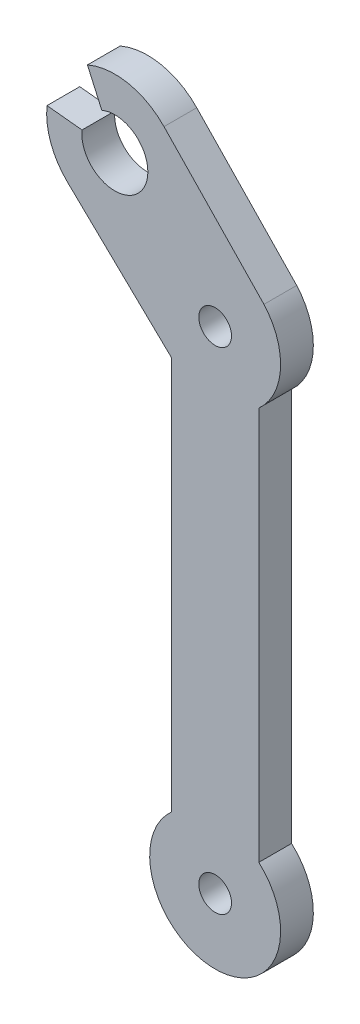
from build123d import *

# Parameters (mm, degrees)
ESQUISSE1_R        = 1.5
BOSS_EXTRU_1_DEPTH = 3


with BuildPart() as part:
    # Esquisse1 → Boss.-Extru.1 (new body)
    with BuildSketch(Plane.XY):
        with BuildLine():
            Line((-10.438754388, 20.283961606), (-10.438754388, -0.112631187))
            Line((-10.438754388, -0.112631187), (-10.438754388, -15.771766484))
            ThreePointArc((-10.438754388, -15.771766484), (-6.438754388, -26.243902439), (-2.438754388, -15.771766484))
            Line((-2.438754388, -15.771766484), (-2.438754388, 20.283961606))
            ThreePointArc((-2.438754388, 20.283961606), (-0.448049603, 24.422247026), (-1.966618433, 28.756097561))
            Line((-1.966618433, 28.756097561), (-2.267139353, 29.068594286))
            Line((-2.267139353, 29.068594286), (-11.126247763, 38.28073952))
            ThreePointArc((-11.126247763, 38.28073952), (-14.416088568, 40.079239654), (-18.143198107, 39.671428739))
            Line((-18.143198107, 39.671428739), (-16.826364742, 36.727346795))
            ThreePointArc((-16.826364742, 36.727346795), (-13.967550368, 36.474962725), (-12.606142543, 33.948485716))
            ThreePointArc((-12.606142543, 33.948485716), (-15.786873062, 30.92749697), (-18.640108166, 34.259533746))
            Line((-18.640108166, 34.259533746), (-21.848013666, 34.591146934))
            ThreePointArc((-21.848013666, 34.591146934), (-21.500157994, 31.799728487), (-19.963396347, 29.443590936))
            Line((-19.963396347, 29.443590936), (-10.751251112, 20.584482526))
            Line((-10.751251112, 20.584482526), (-10.438754388, 20.283961606))
        make_face()
        with Locations((-6.438754388, -20.243902439)):
            Circle(ESQUISSE1_R, mode=Mode.SUBTRACT)
        with Locations((-6.438754388, 24.756097561)):
            Circle(ESQUISSE1_R, mode=Mode.SUBTRACT)
    extrude(amount=BOSS_EXTRU_1_DEPTH)


solid = part.part
